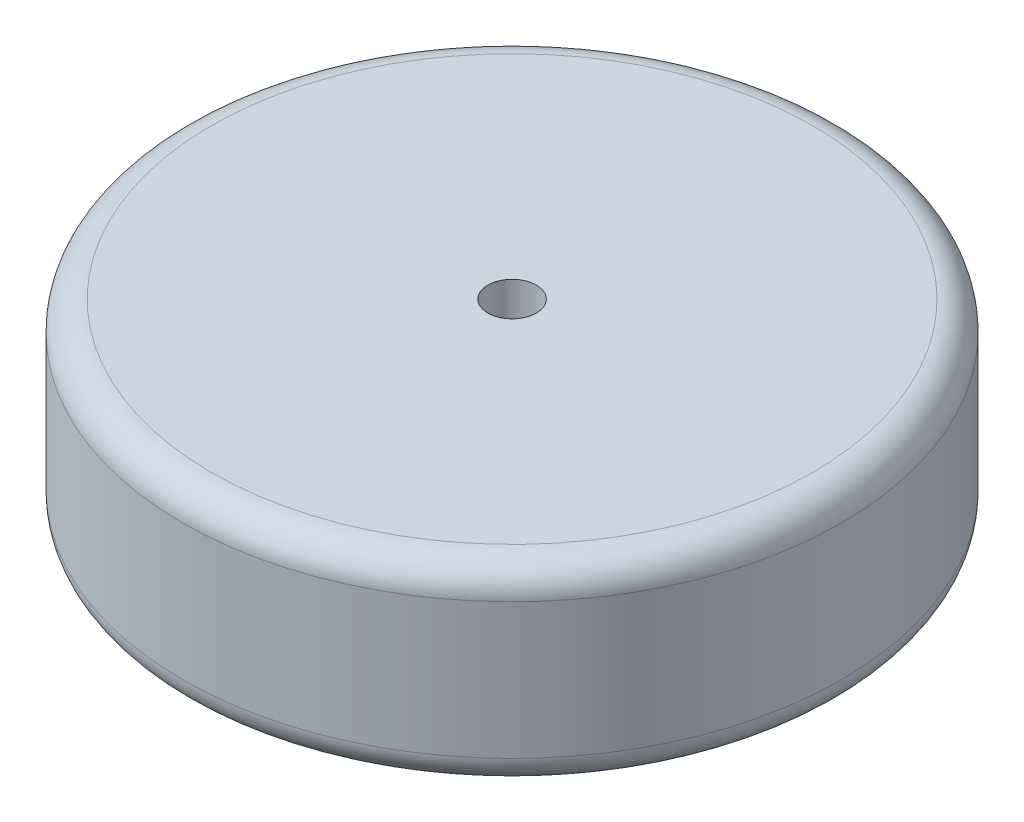
from build123d import *

# Parameters (mm, degrees)
SKETCH_1_R      = 34
SKETCH_1_R_2    = 2.5
EXTRUDE_1_DEPTH = 20
FILLET_1_R      = 3


with BuildPart() as part:
    # 草圖1 → 填料-伸長1 (new body)
    with BuildSketch(Plane(origin=(0, 0, 0), x_dir=(1, 0, 0), z_dir=(0, 1, 0))):
        Circle(SKETCH_1_R)
        Circle(SKETCH_1_R_2, mode=Mode.SUBTRACT)
    extrude(amount=EXTRUDE_1_DEPTH)

    # 圓角1
    fillet_1_edges = [part.edges().sort_by_distance(p)[0] for p in [
        (-34, 0, 0),
        (-34, 20, 0),
    ]]
    fillet(fillet_1_edges, radius=FILLET_1_R)


solid = part.part
